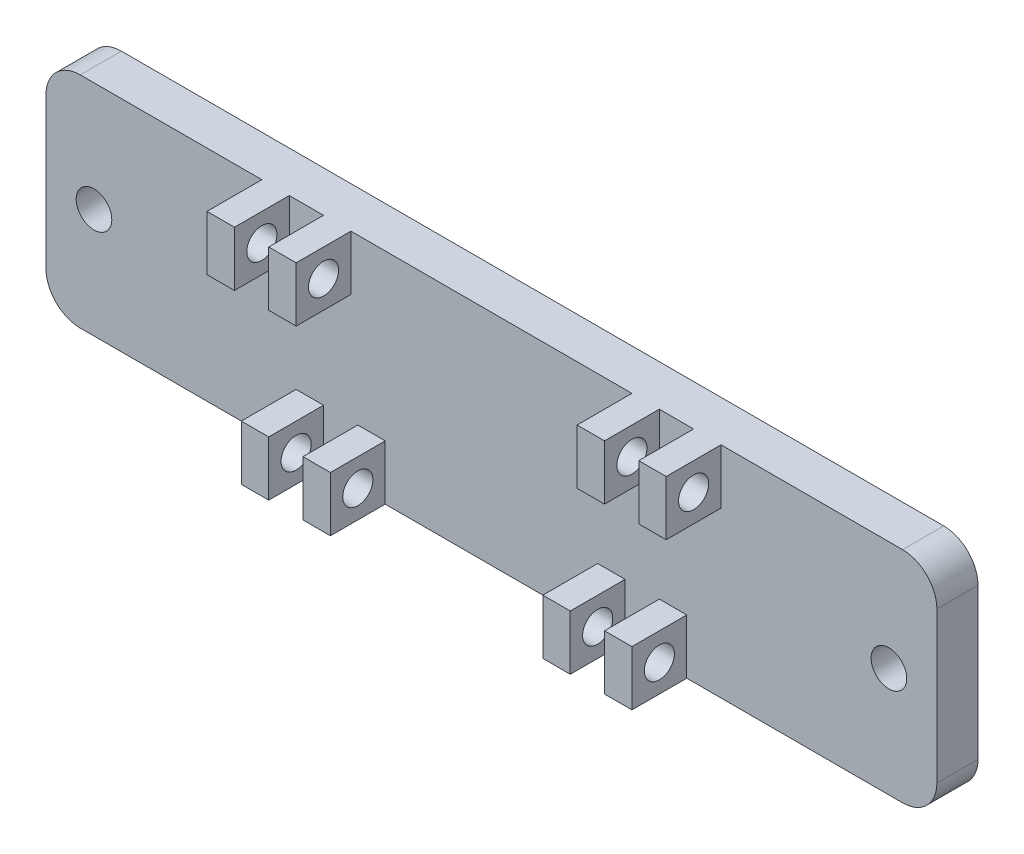
from build123d import *

# Parameters (mm, degrees)
SKETCH_2_R          = 1.3
EXTRUDE_2_DEPTH     = 3
SKETCH_4_W          = 2
SKETCH_4_H          = 4
EXTRUDE_3_DEPTH     = 4
SKETCH_6_R          = 1.1
CUT_EXTRUDE_2_DEPTH = 50.25


with BuildPart() as part:
    # 草图2 → 凸台-拉伸2 (new body)
    with BuildSketch(Plane.XY):
        with BuildLine():
            Line((-3.5, -10), (-3.5, 1))
            ThreePointArc((-3.5, 1), (-2.767766953, 2.767766953), (-1, 3.5))
            Line((-1, 3.5), (59, 3.5))
            ThreePointArc((59, 3.5), (60.767766953, 2.767766953), (61.5, 1))
            Line((61.5, 1), (61.5, -10))
            ThreePointArc((61.5, -10), (60.767766953, -11.767766953), (59, -12.5))
            Line((59, -12.5), (-1, -12.5))
            ThreePointArc((-1, -12.5), (-2.767766953, -11.767766953), (-3.5, -10))
        make_face()
        with Locations((58, -4.5)):
            Circle(SKETCH_2_R, mode=Mode.SUBTRACT)
        with Locations((0, -4.5)):
            Circle(SKETCH_2_R, mode=Mode.SUBTRACT)
    extrude(amount=EXTRUDE_2_DEPTH)

    # 草图4 → 凸台-拉伸3 (add)
    with BuildSketch(Plane.XY.offset(3)):
        with Locations((13.25, 1.5)):
            Rectangle(SKETCH_4_W, SKETCH_4_H)
        with Locations((17.75, 1.5)):
            Rectangle(SKETCH_4_W, SKETCH_4_H)
        with Locations((40.25, 1.5)):
            Rectangle(SKETCH_4_W, SKETCH_4_H)
        with Locations((44.75, 1.5)):
            Rectangle(SKETCH_4_W, SKETCH_4_H)
        with Locations((15.75, -10.5)):
            Rectangle(SKETCH_4_W, SKETCH_4_H)
        with Locations((20.25, -10.5)):
            Rectangle(SKETCH_4_W, SKETCH_4_H)
        with Locations((37.75, -10.5)):
            Rectangle(SKETCH_4_W, SKETCH_4_H)
        with Locations((42.25, -10.5)):
            Rectangle(SKETCH_4_W, SKETCH_4_H)
    extrude(amount=EXTRUDE_3_DEPTH)

    # 草图6 → 切除-拉伸2 (cut, through all)
    with BuildSketch(Plane.ZY.offset(-12.25)):
        with Locations((5, 1.5)):
            Circle(SKETCH_6_R)
        with Locations((5, -10.5)):
            Circle(SKETCH_6_R)
    extrude(amount=-CUT_EXTRUDE_2_DEPTH, mode=Mode.SUBTRACT)


solid = part.part
